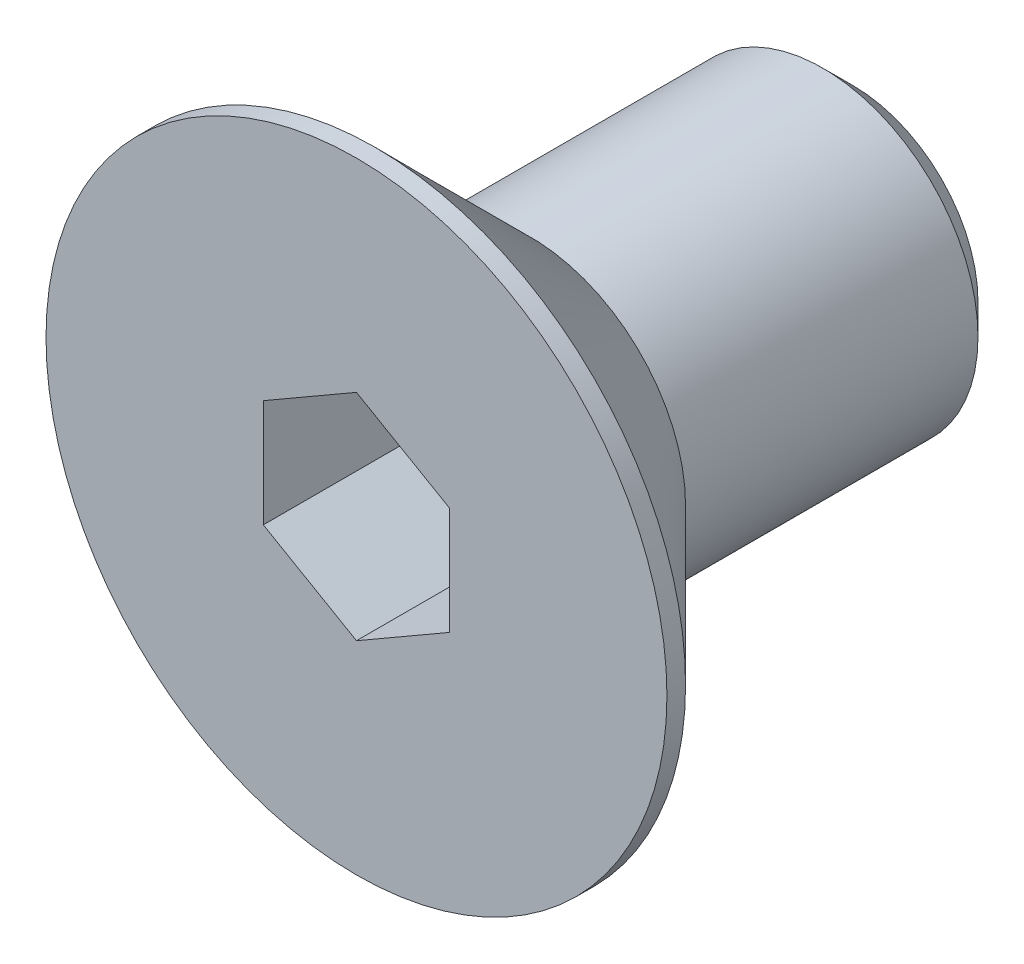
from build123d import *

# Parameters (mm, degrees)
EXTRUDE1_DEPTH = 2.24
CHAMFER1_SIZE  = 0.4905


with BuildPart() as part:
    # Sketch1 → Revolve1 (revolve)
    with BuildSketch(Plane.XZ.offset(-28.4)):
        Polygon((-11, -2), (-16, -2), (-16, -10), (-13.5, -10), (-13.5, -4.8), (-11, -2.3), align=None)
    revolve(axis=Axis((-16, 28.4, -2), (0, 0, -1)))

    # Sketch2 → Extrude1 (cut)
    with BuildSketch(Plane.XY.offset(-2)):
        Polygon((-17.5, 29.266025404), (-17.5, 27.533974596), (-16, 26.667949192), (-14.5, 27.533974596), (-14.5, 29.266025404), (-16, 30.132050808), align=None)
    extrude(amount=-EXTRUDE1_DEPTH, mode=Mode.SUBTRACT)

    # Sketch3 → Cut-Revolve1 (revolve, cut)
    with BuildSketch(Plane.XZ.offset(-28.4)):
        Polygon((-14.5, -4.24), (-16, -4.24), (-16, -4.641923789), align=None)
    revolve(axis=Axis((-16, 28.4, -4.239975), (0, 0, -1)), mode=Mode.SUBTRACT)

    # Chamfer1
    chamfer1_edges = [part.edges().sort_by_distance(p)[0] for p in [
        (-18.5, 28.4, -10),
    ]]
    chamfer(chamfer1_edges, length=CHAMFER1_SIZE)


solid = part.part
